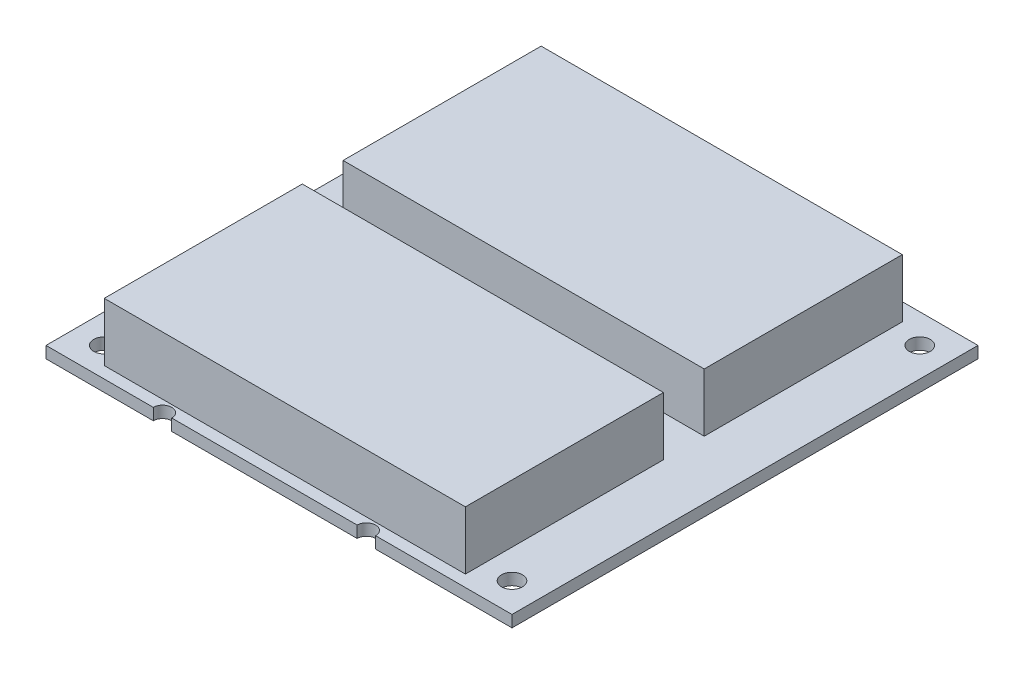
from build123d import *

# Parameters (mm, degrees)
SKETCH1_W                     = 80
SKETCH1_H                     = 80
PCB_DEPTH                     = 2
SKETCH3_W                     = 62
SKETCH3_H                     = 34
BATTERY_STACK_DEPTH           = 10
LPATTERN3_COUNT               = 2
LPATTERN3_PITCH               = 41
SKETCH4_R                     = 1.8
ATTACHMENT_HOLES_DEPTH        = 3
SKETCH6_R                     = 1.5875
BATTERY_CABLE_TIE_HOLES_DEPTH = 3
LPATTERN2_COUNT               = 2
LPATTERN2_PITCH               = 35
LPATTERN2_COUNT_DIR2          = 3
LPATTERN2_PITCH_DIR2          = 40


with BuildPart() as part:
    # Sketch1 → PCB (new body)
    with BuildSketch(Plane(origin=(0, 0, 0), x_dir=(1, 0, 0), z_dir=(0, 1, 0))):
        with Locations((40, 40)):
            Rectangle(SKETCH1_W, SKETCH1_H)
    extrude(amount=PCB_DEPTH)

    # Sketch3 → Battery Stack (add)
    with BuildSketch(Plane(origin=(0, 2, 0), x_dir=(1, 0, 0), z_dir=(0, 1, 0))):
        with Locations((39, 19)):
            Rectangle(SKETCH3_W, SKETCH3_H)
    battery_stack = extrude(amount=BATTERY_STACK_DEPTH)

    # LPattern3: Battery Stack ×2
    with Locations(*[(0, 0, -i * LPATTERN3_PITCH) for i in range(1, LPATTERN3_COUNT)]):
        add(battery_stack)

    # Sketch4 → Attachment holes (cut, through all)
    with BuildSketch(Plane(origin=(0, 2, 0), x_dir=(1, 0, 0), z_dir=(0, 1, 0))):
        with Locations((5, 75)):
            Circle(SKETCH4_R)
        with Locations((75, 75)):
            Circle(SKETCH4_R)
        with Locations((75, 5)):
            Circle(SKETCH4_R)
        with Locations((5, 5)):
            Circle(SKETCH4_R)
    extrude(amount=-ATTACHMENT_HOLES_DEPTH, mode=Mode.SUBTRACT)

    # Sketch6 → Battery Cable Tie Holes (cut, through all)
    with BuildSketch(Plane(origin=(0, 2, 0), x_dir=(1, 0, 0), z_dir=(0, 1, 0))):
        with Locations((20, 0)):
            Circle(SKETCH6_R)
    battery_cable_tie_holes = extrude(amount=-BATTERY_CABLE_TIE_HOLES_DEPTH, mode=Mode.SUBTRACT)

    # LPattern2: Battery Cable Tie Holes 2 × 3
    with Locations(*[(i * LPATTERN2_PITCH, 0, -j * LPATTERN2_PITCH_DIR2) for i in range(LPATTERN2_COUNT) for j in range(LPATTERN2_COUNT_DIR2) if (i, j) != (0, 0)]):
        add(battery_cable_tie_holes, mode=Mode.SUBTRACT)


solid = part.part
